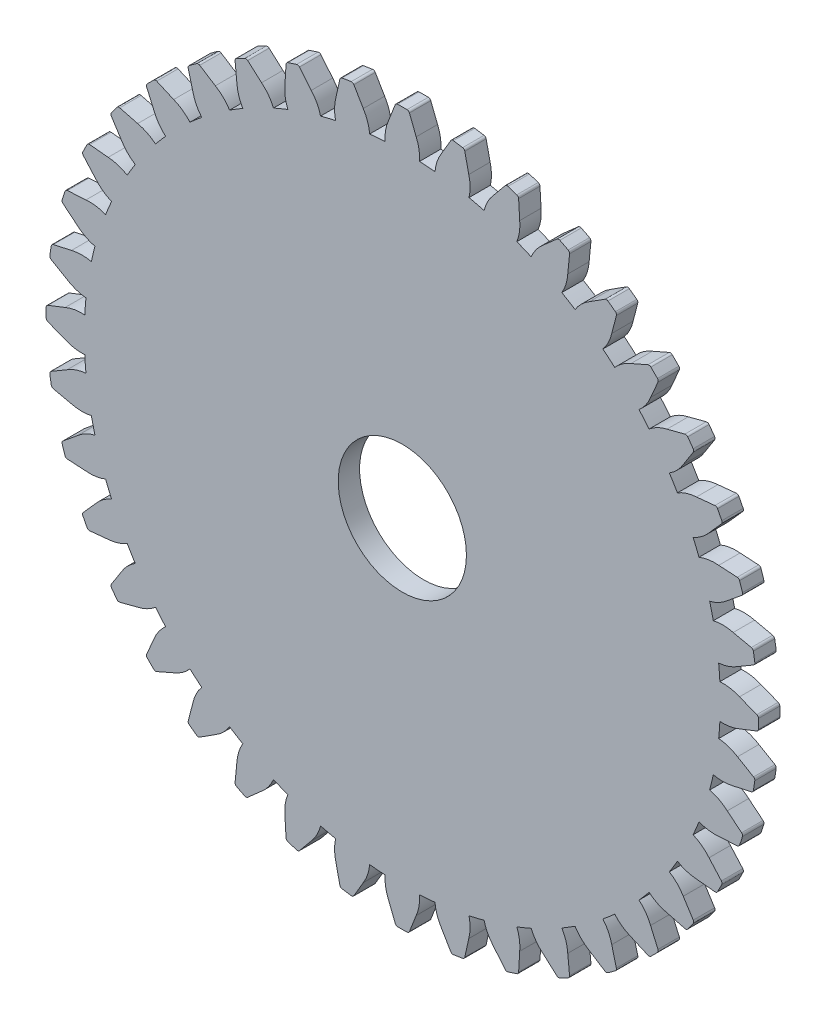
from build123d import *

# Parameters (mm, degrees)
MODEL_R             = 6
BOSS_EXTRUDE1_DEPTH = 2


with BuildPart() as part:
    # Model → Boss-Extrude1 (new body)
    with BuildSketch(Plane.XY):
        with BuildLine():
            ThreePointArc((70.0716993, 43.092854601), (70.049845694, 43.455130485), (70.023576538, 43.817112981))
            ThreePointArc((70.023576538, 43.817112981), (69.992895739, 44.178748273), (69.957807857, 44.539982597))
            ThreePointArc((69.957807857, 44.539982597), (70.876932331, 44.731527399), (71.723910096, 45.136629701))
            ThreePointArc((71.723910096, 45.136629701), (72.472755382, 45.575792344), (73.221545221, 46.015049518))
            ThreePointArc((73.221545221, 46.015049518), (73.320101406, 46.122090017), (73.342139687, 46.265913882))
            ThreePointArc((73.342139687, 46.265913882), (73.310158709, 46.481495249), (73.276769081, 46.696862938))
            ThreePointArc((73.276769081, 46.696862938), (73.241972229, 46.912007745), (73.20576964, 47.126920474))
            ThreePointArc((73.20576964, 47.126920474), (73.14036597, 47.256894894), (73.013556136, 47.328240923))
            ThreePointArc((73.013556136, 47.328240923), (72.165676748, 47.514610535), (71.317773839, 47.700873108))
            ThreePointArc((71.317773839, 47.700873108), (70.387066621, 47.824417769), (69.453736701, 47.722562619))
            ThreePointArc((69.453736701, 47.722562619), (69.375479715, 48.076959629), (69.292907438, 48.430376118))
            ThreePointArc((69.292907438, 48.430376118), (69.206032147, 48.782759545), (69.114866756, 49.134057521))
            ThreePointArc((69.114866756, 49.134057521), (69.992711075, 49.467026835), (70.765889176, 49.999638169))
            ThreePointArc((70.765889176, 49.999638169), (71.436814761, 50.550539202), (72.107670794, 51.10152493))
            ThreePointArc((72.107670794, 51.10152493), (72.188268765, 51.222665166), (72.187536709, 51.368165867))
            ThreePointArc((72.187536709, 51.368165867), (72.122225114, 51.576090143), (72.055555638, 51.78358301))
            ThreePointArc((72.055555638, 51.78358301), (71.98753113, 51.9906356), (71.918154497, 52.197239064))
            ThreePointArc((71.918154497, 52.197239064), (71.833223577, 52.315381896), (71.696814004, 52.366012107))
            ThreePointArc((71.696814004, 52.366012107), (70.830218788, 52.417449642), (69.963617085, 52.468777776))
            ThreePointArc((69.963617085, 52.468777776), (69.025041774, 52.445206711), (68.11913635, 52.198600601))
            ThreePointArc((68.11913635, 52.198600601), (67.986402931, 52.536392305), (67.849560736, 52.872540501))
            ThreePointArc((67.849560736, 52.872540501), (67.708630111, 53.206995214), (67.563632007, 53.539706719))
            ThreePointArc((67.563632007, 53.539706719), (68.378580728, 54.005901734), (69.058920956, 54.652907442))
            ThreePointArc((69.058920956, 54.652907442), (69.635406425, 55.301981854), (70.211809949, 55.951129038))
            ThreePointArc((70.211809949, 55.951129038), (70.272465117, 56.083386138), (70.248980749, 56.226980965))
            ThreePointArc((70.248980749, 56.226980965), (70.151946726, 56.422128363), (70.053639027, 56.616637245))
            ThreePointArc((70.053639027, 56.616637245), (69.954061852, 56.810499296), (69.853219458, 57.003706233))
            ThreePointArc((69.853219458, 57.003706233), (69.750852567, 57.107108407), (69.608202113, 57.135776118))
            ThreePointArc((69.608202113, 57.135776118), (68.744229518, 57.051015013), (67.880267631, 56.966144838))
            ThreePointArc((67.880267631, 56.966144838), (66.956935066, 56.796038446), (66.100760537, 56.410753635))
            ThreePointArc((66.100760537, 56.410753635), (65.916819022, 56.723622481), (65.729076419, 57.0342253))
            ThreePointArc((65.729076419, 57.0342253), (65.537560639, 57.342515913), (65.342300156, 57.648448487))
            ThreePointArc((65.342300156, 57.648448487), (66.074286538, 58.236389935), (66.645036657, 58.981858588))
            ThreePointArc((66.645036657, 58.981858588), (67.112887025, 59.713124013), (67.580645072, 60.444448495))
            ThreePointArc((67.580645072, 60.444448495), (67.619863906, 60.584565849), (67.57420549, 60.722719022))
            ThreePointArc((67.57420549, 60.722719022), (67.447838338, 60.900284366), (67.320313076, 61.077019808))
            ThreePointArc((67.320313076, 61.077019808), (67.191635156, 61.252917794), (67.061810075, 61.427970806))
            ThreePointArc((67.061810075, 61.427970806), (66.944527827, 61.514086218), (66.799149018, 61.520085535))
            ThreePointArc((66.799149018, 61.520085535), (65.959072918, 61.301212889), (65.119024456, 61.082234191))
            ThreePointArc((65.119024456, 61.082234191), (64.23367015, 60.769781055), (63.448308373, 60.255304535))
            ThreePointArc((63.448308373, 60.255304535), (63.217688012, 60.535546654), (62.983667846, 60.812956023))
            ThreePointArc((62.983667846, 60.812956023), (62.746282667, 61.087491399), (62.505567765, 61.359111966))
            ThreePointArc((62.505567765, 61.359111966), (63.136567875, 62.054322777), (63.583674122, 62.879898464))
            ThreePointArc((63.583674122, 62.879898464), (63.93136936, 63.67534872), (64.278964176, 64.470842864))
            ThreePointArc((64.278964176, 64.470842864), (64.295780977, 64.615370318), (64.229072775, 64.744680046))
            ThreePointArc((64.229072775, 64.744680046), (64.076484072, 64.900291088), (63.922881344, 65.054901278))
            ThreePointArc((63.922881344, 65.054901278), (63.768271155, 65.208504006), (63.612660112, 65.361092708))
            ThreePointArc((63.612660112, 65.361092708), (63.483350385, 65.427800911), (63.33882293, 65.410984109))
            ThreePointArc((63.33882293, 65.410984109), (62.543328787, 65.063389294), (61.747878531, 64.715694056))
            ThreePointArc((61.747878531, 64.715694056), (60.922302844, 64.268587808), (60.227092033, 63.637587699))
            ThreePointArc((60.227092033, 63.637587699), (59.955471466, 63.8783026), (59.68093609, 64.11568778))
            ThreePointArc((59.68093609, 64.11568778), (59.403526721, 64.349707946), (59.123284602, 64.580328306))
            ThreePointArc((59.123284602, 64.580328306), (59.637761122, 65.365690083), (59.950214258, 66.251044389))
            ThreePointArc((59.950214258, 66.251044389), (60.169192956, 67.091092852), (60.388065602, 67.931168951))
            ThreePointArc((60.388065602, 67.931168951), (60.382066285, 68.07654776), (60.295950873, 68.193830008))
            ThreePointArc((60.295950873, 68.193830008), (60.120897861, 68.323655089), (59.944999875, 68.45233301))
            ThreePointArc((59.944999875, 68.45233301), (59.768264433, 68.579858271), (59.590699088, 68.706225423))
            ThreePointArc((59.590699088, 68.706225423), (59.452545916, 68.751883839), (59.312428562, 68.712665005))
            ThreePointArc((59.312428562, 68.712665005), (58.58110408, 68.244906958), (57.849838655, 67.77705659))
            ThreePointArc((57.849838655, 67.77705659), (57.104370002, 67.206306472), (56.516428554, 66.474320089))
            ThreePointArc((56.516428554, 66.474320089), (56.21049598, 66.669580572), (55.902205367, 66.861096352))
            ThreePointArc((55.902205367, 66.861096352), (55.591602548, 67.048838955), (55.278733702, 67.23278047))
            ThreePointArc((55.278733702, 67.23278047), (55.664018512, 68.088955), (55.834124905, 69.012287565))
            ThreePointArc((55.834124905, 69.012287565), (55.918995079, 69.876249452), (56.003756185, 70.740222046))
            ThreePointArc((56.003756185, 70.740222046), (55.975088474, 70.882872501), (55.8716863, 70.985239391))
            ThreePointArc((55.8716863, 70.985239391), (55.678479363, 71.086081785), (55.484617312, 71.18565896))
            ThreePointArc((55.484617312, 71.18565896), (55.29010843, 71.283966659), (55.094961032, 71.381000682))
            ThreePointArc((55.094961032, 71.381000682), (54.951366205, 71.40448505), (54.819109105, 71.343829882))
            ThreePointArc((54.819109105, 71.343829882), (54.169961921, 70.767426358), (53.520887509, 70.190940889))
            ThreePointArc((53.520887509, 70.190940889), (52.873881801, 69.510600662), (52.407686786, 68.69565194))
            ThreePointArc((52.407686786, 68.69565194), (52.074975281, 68.840650044), (51.740520568, 68.98158067))
            ThreePointArc((51.740520568, 68.98158067), (51.404372372, 69.118422864), (51.066580667, 69.251156283))
            ThreePointArc((51.066580667, 69.251156283), (51.313186778, 70.157061707), (51.336757843, 71.095637018))
            ThreePointArc((51.336757843, 71.095637018), (51.285429709, 71.962238721), (51.233992174, 72.828833937))
            ThreePointArc((51.233992174, 72.828833937), (51.183361962, 72.96524351), (51.065219131, 73.050174431))
            ThreePointArc((51.065219131, 73.050174431), (50.858615666, 73.119551064), (50.651563076, 73.187575572))
            ThreePointArc((50.651563076, 73.187575572), (50.44407021, 73.254245048), (50.236145934, 73.319556642))
            ThreePointArc((50.236145934, 73.319556642), (50.090645233, 73.320288698), (49.969504996, 73.239690727))
            ThreePointArc((49.969504996, 73.239690727), (49.418519269, 72.568834694), (48.867618235, 71.897909109))
            ThreePointArc((48.867618235, 71.897909109), (48.335006901, 71.124731008), (48.002037588, 70.24688669))
            ThreePointArc((48.002037588, 70.24688669), (47.650739612, 70.33805208), (47.298356185, 70.424927372))
            ThreePointArc((47.298356185, 70.424927372), (46.944939695, 70.507499648), (46.590542686, 70.585756634))
            ThreePointArc((46.590542686, 70.585756634), (46.692397836, 71.519086554), (46.568853175, 72.449793773))
            ThreePointArc((46.568853175, 72.449793773), (46.382590602, 73.297696681), (46.196220989, 74.145576069))
            ThreePointArc((46.196220989, 74.145576069), (46.124874961, 74.272385903), (45.994900541, 74.337789573))
            ThreePointArc((45.994900541, 74.337789573), (45.779987811, 74.373992162), (45.564843005, 74.408789014))
            ThreePointArc((45.564843005, 74.408789014), (45.349475316, 74.442178643), (45.133893949, 74.47415962))
            ThreePointArc((45.133893949, 74.47415962), (44.990070084, 74.452121339), (44.883029585, 74.353565154))
            ThreePointArc((44.883029585, 74.353565154), (44.44377241, 73.604775315), (44.004609768, 72.85593003))
            ThreePointArc((44.004609768, 72.85593003), (43.599507466, 72.008952264), (43.407962664, 71.08982779))
            ThreePointArc((43.407962664, 71.08982779), (43.04672834, 71.124915672), (42.685093048, 71.155596472))
            ThreePointArc((42.685093048, 71.155596472), (42.323110552, 71.181865627), (41.960834668, 71.203719233))
            ThreePointArc((41.960834668, 71.203719233), (41.915430845, 72.141491969), (41.647812538, 73.041413994))
            ThreePointArc((41.647812538, 73.041413994), (41.331201929, 73.849739925), (41.014489277, 74.65802588))
            ThreePointArc((41.014489277, 74.65802588), (40.924184208, 74.772113497), (40.7855786, 74.81637946))
            ThreePointArc((40.7855786, 74.81637946), (40.56764847, 74.818516577), (40.349709026, 74.81922896))
            ThreePointArc((40.349709026, 74.81922896), (40.131769583, 74.818516577), (39.913839453, 74.81637946))
            ThreePointArc((39.913839453, 74.81637946), (39.775233845, 74.772113497), (39.684928776, 74.65802588))
            ThreePointArc((39.684928776, 74.65802588), (39.368216124, 73.849739925), (39.051605515, 73.041413994))
            ThreePointArc((39.051605515, 73.041413994), (38.783987208, 72.141491968), (38.738583385, 71.203719233))
            ThreePointArc((38.738583385, 71.203719233), (38.376307501, 71.181865627), (38.014325005, 71.155596472))
            ThreePointArc((38.014325005, 71.155596472), (37.652689713, 71.124915672), (37.291455389, 71.08982779))
            ThreePointArc((37.291455389, 71.08982779), (37.099910587, 72.008952264), (36.694808285, 72.85593003))
            ThreePointArc((36.694808285, 72.85593003), (36.255645643, 73.604775315), (35.816388468, 74.353565154))
            ThreePointArc((35.816388468, 74.353565154), (35.709347969, 74.452121339), (35.565524104, 74.47415962))
            ThreePointArc((35.565524104, 74.47415962), (35.349942737, 74.442178643), (35.134575048, 74.408789014))
            ThreePointArc((35.134575048, 74.408789014), (34.919430242, 74.373992162), (34.704517512, 74.337789573))
            ThreePointArc((34.704517512, 74.337789573), (34.574543092, 74.272385903), (34.503197064, 74.145576069))
            ThreePointArc((34.503197064, 74.145576069), (34.316827451, 73.297696681), (34.130564878, 72.449793773))
            ThreePointArc((34.130564878, 72.449793773), (34.007020217, 71.519086554), (34.108875367, 70.585756634))
            ThreePointArc((34.108875367, 70.585756634), (33.754478358, 70.507499648), (33.401061868, 70.424927372))
            ThreePointArc((33.401061868, 70.424927372), (33.048678441, 70.33805208), (32.697380465, 70.24688669))
            ThreePointArc((32.697380465, 70.24688669), (32.364411152, 71.124731008), (31.831799817, 71.89790911))
            ThreePointArc((31.831799817, 71.89790911), (31.280898784, 72.568834694), (30.729913057, 73.239690727))
            ThreePointArc((30.729913057, 73.239690727), (30.60877282, 73.320288698), (30.463272119, 73.319556642))
            ThreePointArc((30.463272119, 73.319556642), (30.255347843, 73.254245048), (30.047854976, 73.187575572))
            ThreePointArc((30.047854976, 73.187575572), (29.840802386, 73.119551064), (29.634198922, 73.050174431))
            ThreePointArc((29.634198922, 73.050174431), (29.516056091, 72.96524351), (29.465425879, 72.828833937))
            ThreePointArc((29.465425879, 72.828833937), (29.413988344, 71.962238721), (29.36266021, 71.095637018))
            ThreePointArc((29.36266021, 71.095637018), (29.386231275, 70.157061707), (29.632837386, 69.251156283))
            ThreePointArc((29.632837386, 69.251156283), (29.295045681, 69.118422864), (28.958897485, 68.98158067))
            ThreePointArc((28.958897485, 68.98158067), (28.624442772, 68.840650044), (28.291731267, 68.69565194))
            ThreePointArc((28.291731267, 68.69565194), (27.825536252, 69.510600662), (27.178530544, 70.190940889))
            ThreePointArc((27.178530544, 70.190940889), (26.529456132, 70.767426358), (25.880308948, 71.343829882))
            ThreePointArc((25.880308948, 71.343829882), (25.748051848, 71.40448505), (25.604457021, 71.381000682))
            ThreePointArc((25.604457021, 71.381000682), (25.409309623, 71.283966659), (25.214800741, 71.18565896))
            ThreePointArc((25.214800741, 71.18565896), (25.02093869, 71.086081785), (24.827731753, 70.985239391))
            ThreePointArc((24.827731753, 70.985239391), (24.724329579, 70.882872501), (24.695661868, 70.740222046))
            ThreePointArc((24.695661868, 70.740222046), (24.780422974, 69.876249452), (24.865293148, 69.012287565))
            ThreePointArc((24.865293148, 69.012287565), (25.035399541, 68.088955), (25.420684351, 67.23278047))
            ThreePointArc((25.420684351, 67.23278047), (25.107815505, 67.048838955), (24.797212686, 66.861096352))
            ThreePointArc((24.797212686, 66.861096352), (24.488922073, 66.669580572), (24.182989499, 66.474320089))
            ThreePointArc((24.182989499, 66.474320089), (23.595048051, 67.206306472), (22.849579398, 67.77705659))
            ThreePointArc((22.849579398, 67.77705659), (22.118313973, 68.244906958), (21.386989491, 68.712665005))
            ThreePointArc((21.386989491, 68.712665005), (21.246872137, 68.751883839), (21.108718965, 68.706225423))
            ThreePointArc((21.108718965, 68.706225423), (20.93115362, 68.579858271), (20.754418178, 68.45233301))
            ThreePointArc((20.754418178, 68.45233301), (20.578520192, 68.323655089), (20.40346718, 68.193830008))
            ThreePointArc((20.40346718, 68.193830008), (20.317351768, 68.07654776), (20.311352451, 67.931168951))
            ThreePointArc((20.311352451, 67.931168951), (20.530225097, 67.091092852), (20.749203795, 66.251044389))
            ThreePointArc((20.749203795, 66.251044389), (21.061656931, 65.365690083), (21.576133451, 64.580328306))
            ThreePointArc((21.576133451, 64.580328306), (21.295891332, 64.349707946), (21.018481963, 64.11568778))
            ThreePointArc((21.018481963, 64.11568778), (20.743946587, 63.8783026), (20.47232602, 63.637587699))
            ThreePointArc((20.47232602, 63.637587699), (19.777115209, 64.268587808), (18.951539522, 64.715694056))
            ThreePointArc((18.951539522, 64.715694056), (18.156089266, 65.063389294), (17.360595123, 65.410984109))
            ThreePointArc((17.360595123, 65.410984109), (17.216067668, 65.427800911), (17.086757941, 65.361092708))
            ThreePointArc((17.086757941, 65.361092708), (16.931146898, 65.208504006), (16.776536709, 65.054901278))
            ThreePointArc((16.776536709, 65.054901278), (16.622933981, 64.900291088), (16.470345278, 64.744680046))
            ThreePointArc((16.470345278, 64.744680046), (16.403637076, 64.615370318), (16.420453877, 64.470842864))
            ThreePointArc((16.420453877, 64.470842864), (16.768048693, 63.67534872), (17.115743931, 62.879898464))
            ThreePointArc((17.115743931, 62.879898464), (17.562850178, 62.054322777), (18.193850288, 61.359111966))
            ThreePointArc((18.193850288, 61.359111966), (17.953135386, 61.087491399), (17.715750207, 60.812956023))
            ThreePointArc((17.715750207, 60.812956023), (17.481730041, 60.535546654), (17.25110968, 60.255304535))
            ThreePointArc((17.25110968, 60.255304535), (16.465747903, 60.769781055), (15.580393597, 61.082234191))
            ThreePointArc((15.580393597, 61.082234191), (14.740345135, 61.301212889), (13.900269035, 61.520085535))
            ThreePointArc((13.900269035, 61.520085535), (13.754890226, 61.514086218), (13.637607978, 61.427970806))
            ThreePointArc((13.637607978, 61.427970806), (13.507782897, 61.252917794), (13.379104976, 61.077019808))
            ThreePointArc((13.379104976, 61.077019808), (13.251579715, 60.900284366), (13.125212563, 60.722719022))
            ThreePointArc((13.125212563, 60.722719022), (13.079554147, 60.584565849), (13.118772981, 60.444448495))
            ThreePointArc((13.118772981, 60.444448495), (13.586531028, 59.713124013), (14.054381396, 58.981858588))
            ThreePointArc((14.054381396, 58.981858588), (14.625131515, 58.236389935), (15.357117897, 57.648448487))
            ThreePointArc((15.357117897, 57.648448487), (15.161857414, 57.342515913), (14.970341634, 57.0342253))
            ThreePointArc((14.970341634, 57.0342253), (14.782599031, 56.723622481), (14.598657516, 56.410753635))
            ThreePointArc((14.598657516, 56.410753635), (13.742482987, 56.796038446), (12.819150421, 56.966144838))
            ThreePointArc((12.819150421, 56.966144838), (11.955188535, 57.051015013), (11.09121594, 57.135776118))
            ThreePointArc((11.09121594, 57.135776118), (10.948565486, 57.107108407), (10.846198595, 57.003706233))
            ThreePointArc((10.846198595, 57.003706233), (10.745356201, 56.810499296), (10.645779026, 56.616637245))
            ThreePointArc((10.645779026, 56.616637245), (10.547471327, 56.422128363), (10.450437304, 56.226980965))
            ThreePointArc((10.450437304, 56.226980965), (10.426952936, 56.083386138), (10.487608104, 55.951129038))
            ThreePointArc((10.487608104, 55.951129038), (11.064011628, 55.301981854), (11.640497097, 54.652907442))
            ThreePointArc((11.640497097, 54.652907442), (12.320837325, 54.005901734), (13.135786046, 53.539706719))
            ThreePointArc((13.135786046, 53.539706719), (12.990787942, 53.206995214), (12.849857317, 52.872540501))
            ThreePointArc((12.849857317, 52.872540501), (12.713015122, 52.536392305), (12.580281703, 52.198600601))
            ThreePointArc((12.580281703, 52.198600601), (11.674376279, 52.445206711), (10.735800968, 52.468777776))
            ThreePointArc((10.735800968, 52.468777776), (9.869199265, 52.417449642), (9.002604049, 52.366012107))
            ThreePointArc((9.002604049, 52.366012107), (8.866194476, 52.315381896), (8.781263556, 52.197239064))
            ThreePointArc((8.781263556, 52.197239064), (8.711886923, 51.9906356), (8.643862414, 51.78358301))
            ThreePointArc((8.643862414, 51.78358301), (8.577192939, 51.576090143), (8.511881344, 51.368165867))
            ThreePointArc((8.511881344, 51.368165867), (8.511149288, 51.222665166), (8.591747259, 51.10152493))
            ThreePointArc((8.591747259, 51.10152493), (9.262603292, 50.550539202), (9.933528877, 49.999638169))
            ThreePointArc((9.933528877, 49.999638169), (10.706706978, 49.467026834), (11.584551297, 49.134057521))
            ThreePointArc((11.584551297, 49.134057521), (11.493385906, 48.782759545), (11.406510615, 48.430376118))
            ThreePointArc((11.406510615, 48.430376118), (11.323938338, 48.076959629), (11.245681352, 47.722562619))
            ThreePointArc((11.245681352, 47.722562619), (10.312351432, 47.824417769), (9.381644214, 47.700873108))
            ThreePointArc((9.381644214, 47.700873108), (8.533741305, 47.514610535), (7.685861917, 47.328240923))
            ThreePointArc((7.685861917, 47.328240923), (7.559052083, 47.256894894), (7.493648413, 47.126920474))
            ThreePointArc((7.493648413, 47.126920474), (7.457445824, 46.912007745), (7.422648972, 46.696862938))
            ThreePointArc((7.422648972, 46.696862938), (7.389259344, 46.481495249), (7.357278366, 46.265913882))
            ThreePointArc((7.357278366, 46.265913882), (7.379316647, 46.122090017), (7.477872832, 46.015049518))
            ThreePointArc((7.477872832, 46.015049518), (8.226662671, 45.575792344), (8.975507957, 45.136629701))
            ThreePointArc((8.975507957, 45.136629701), (9.822485722, 44.731527399), (10.741610196, 44.539982597))
            ThreePointArc((10.741610196, 44.539982597), (10.706522314, 44.178748273), (10.675841515, 43.817112981))
            ThreePointArc((10.675841515, 43.817112981), (10.649572359, 43.455130485), (10.627718753, 43.092854601))
            ThreePointArc((10.627718753, 43.092854601), (9.689946018, 43.047450778), (8.790023992, 42.779832472))
            ThreePointArc((8.790023992, 42.779832472), (7.981698061, 42.463221862), (7.173412107, 42.14650921))
            ThreePointArc((7.173412107, 42.14650921), (7.059324489, 42.056204141), (7.015058526, 41.917598533))
            ThreePointArc((7.015058526, 41.917598533), (7.012921409, 41.699668404), (7.012209026, 41.48172896))
            ThreePointArc((7.012209026, 41.48172896), (7.012921409, 41.263789516), (7.015058526, 41.045859386))
            ThreePointArc((7.015058526, 41.045859386), (7.059324489, 40.907253778), (7.173412107, 40.81694871))
            ThreePointArc((7.173412107, 40.81694871), (7.981698061, 40.500236058), (8.790023992, 40.183625448))
            ThreePointArc((8.790023992, 40.183625448), (9.689946018, 39.916007141), (10.627718753, 39.870603318))
            ThreePointArc((10.627718753, 39.870603318), (10.649572359, 39.508327435), (10.675841515, 39.146344938))
            ThreePointArc((10.675841515, 39.146344938), (10.706522314, 38.784709646), (10.741610196, 38.423475323))
            ThreePointArc((10.741610196, 38.423475323), (9.822485722, 38.23193052), (8.975507957, 37.826828218))
            ThreePointArc((8.975507957, 37.826828218), (8.226662671, 37.387665576), (7.477872832, 36.948408401))
            ThreePointArc((7.477872832, 36.948408401), (7.379316647, 36.841367902), (7.357278366, 36.697544037))
            ThreePointArc((7.357278366, 36.697544037), (7.389259344, 36.48196267), (7.422648972, 36.266594981))
            ThreePointArc((7.422648972, 36.266594981), (7.457445824, 36.051450175), (7.493648413, 35.836537445))
            ThreePointArc((7.493648413, 35.836537445), (7.559052083, 35.706563025), (7.685861917, 35.635216997))
            ThreePointArc((7.685861917, 35.635216997), (8.533741305, 35.448847384), (9.381644213, 35.262584811))
            ThreePointArc((9.381644213, 35.262584811), (10.312351432, 35.13904015), (11.245681352, 35.2408953))
            ThreePointArc((11.245681352, 35.2408953), (11.323938338, 34.886498291), (11.406510615, 34.533081801))
            ThreePointArc((11.406510615, 34.533081801), (11.493385906, 34.180698374), (11.584551297, 33.829400398))
            ThreePointArc((11.584551297, 33.829400398), (10.706706978, 33.496431085), (9.933528877, 32.963819751))
            ThreePointArc((9.933528877, 32.963819751), (9.262603292, 32.412918718), (8.591747259, 31.86193299))
            ThreePointArc((8.591747259, 31.86193299), (8.511149288, 31.740792753), (8.511881344, 31.595292052))
            ThreePointArc((8.511881344, 31.595292052), (8.577192939, 31.387367776), (8.643862414, 31.17987491))
            ThreePointArc((8.643862414, 31.17987491), (8.711886923, 30.97282232), (8.781263556, 30.766218855))
            ThreePointArc((8.781263556, 30.766218855), (8.866194476, 30.648076024), (9.002604049, 30.597445812))
            ThreePointArc((9.002604049, 30.597445812), (9.869199265, 30.546008277), (10.735800968, 30.494680143))
            ThreePointArc((10.735800968, 30.494680143), (11.674376279, 30.518251208), (12.580281703, 30.764857319))
            ThreePointArc((12.580281703, 30.764857319), (12.713015122, 30.427065615), (12.849857317, 30.090917418))
            ThreePointArc((12.849857317, 30.090917418), (12.990787942, 29.756462705), (13.135786046, 29.4237512))
            ThreePointArc((13.135786046, 29.4237512), (12.320837325, 28.957556185), (11.640497097, 28.310550477))
            ThreePointArc((11.640497097, 28.310550477), (11.064011628, 27.661476065), (10.487608104, 27.012328882))
            ThreePointArc((10.487608104, 27.012328882), (10.426952936, 26.880071782), (10.450437304, 26.736476954))
            ThreePointArc((10.450437304, 26.736476954), (10.547471327, 26.541329556), (10.645779026, 26.346820675))
            ThreePointArc((10.645779026, 26.346820675), (10.745356201, 26.152958623), (10.846198595, 25.959751687))
            ThreePointArc((10.846198595, 25.959751687), (10.948565486, 25.856349513), (11.09121594, 25.827681801))
            ThreePointArc((11.09121594, 25.827681801), (11.955188535, 25.912442907), (12.819150421, 25.997313081))
            ThreePointArc((12.819150421, 25.997313081), (13.742482986, 26.167419474), (14.598657516, 26.552704285))
            ThreePointArc((14.598657516, 26.552704285), (14.782599031, 26.239835438), (14.970341634, 25.929232619))
            ThreePointArc((14.970341634, 25.929232619), (15.161857414, 25.620942006), (15.357117897, 25.315009432))
            ThreePointArc((15.357117897, 25.315009432), (14.625131515, 24.727067984), (14.054381396, 23.981599331))
            ThreePointArc((14.054381396, 23.981599331), (13.586531028, 23.250333906), (13.118772981, 22.519009424))
            ThreePointArc((13.118772981, 22.519009424), (13.079554147, 22.37889207), (13.125212563, 22.240738898))
            ThreePointArc((13.125212563, 22.240738898), (13.251579715, 22.063173553), (13.379104976, 21.886438111))
            ThreePointArc((13.379104976, 21.886438111), (13.507782897, 21.710540125), (13.637607978, 21.535487113))
            ThreePointArc((13.637607978, 21.535487113), (13.754890226, 21.449371701), (13.900269035, 21.443372385))
            ThreePointArc((13.900269035, 21.443372385), (14.740345135, 21.662245031), (15.580393597, 21.881223728))
            ThreePointArc((15.580393597, 21.881223728), (16.465747903, 22.193676865), (17.25110968, 22.708153384))
            ThreePointArc((17.25110968, 22.708153384), (17.481730041, 22.427911265), (17.715750207, 22.150501896))
            ThreePointArc((17.715750207, 22.150501896), (17.953135386, 21.87596652), (18.193850288, 21.604345953))
            ThreePointArc((18.193850288, 21.604345953), (17.562850178, 20.909135142), (17.115743931, 20.083559456))
            ThreePointArc((17.115743931, 20.083559456), (16.768048693, 19.2881092), (16.420453877, 18.492615056))
            ThreePointArc((16.420453877, 18.492615056), (16.403637076, 18.348087601), (16.470345278, 18.218777874))
            ThreePointArc((16.470345278, 18.218777874), (16.622933981, 18.063166831), (16.776536709, 17.908556642))
            ThreePointArc((16.776536709, 17.908556642), (16.931146898, 17.754953914), (17.086757941, 17.602365211))
            ThreePointArc((17.086757941, 17.602365211), (17.216067668, 17.535657009), (17.360595123, 17.55247381))
            ThreePointArc((17.360595123, 17.55247381), (18.156089266, 17.900068626), (18.951539522, 18.247763864))
            ThreePointArc((18.951539522, 18.247763864), (19.777115209, 18.694870111), (20.47232602, 19.325870221))
            ThreePointArc((20.47232602, 19.325870221), (20.743946587, 19.08515532), (21.018481963, 18.84777014))
            ThreePointArc((21.018481963, 18.84777014), (21.295891332, 18.613749974), (21.576133451, 18.383129613))
            ThreePointArc((21.576133451, 18.383129613), (21.061656931, 17.597767836), (20.749203795, 16.71241353))
            ThreePointArc((20.749203795, 16.71241353), (20.530225097, 15.872365068), (20.311352451, 15.032288968))
            ThreePointArc((20.311352451, 15.032288968), (20.317351768, 14.886910159), (20.40346718, 14.769627911))
            ThreePointArc((20.40346718, 14.769627911), (20.578520192, 14.63980283), (20.754418178, 14.51112491))
            ThreePointArc((20.754418178, 14.51112491), (20.93115362, 14.383599648), (21.108718965, 14.257232496))
            ThreePointArc((21.108718965, 14.257232496), (21.246872137, 14.21157408), (21.386989491, 14.250792914))
            ThreePointArc((21.386989491, 14.250792914), (22.118313973, 14.718550962), (22.849579398, 15.18640133))
            ThreePointArc((22.849579398, 15.18640133), (23.595048051, 15.757151448), (24.182989499, 16.48913783))
            ThreePointArc((24.182989499, 16.48913783), (24.488922073, 16.293877347), (24.797212686, 16.102361568))
            ThreePointArc((24.797212686, 16.102361568), (25.107815505, 15.914618964), (25.420684351, 15.730677449))
            ThreePointArc((25.420684351, 15.730677449), (25.035399541, 14.87450292), (24.865293148, 13.951170355))
            ThreePointArc((24.865293148, 13.951170355), (24.780422974, 13.087208468), (24.695661868, 12.223235874))
            ThreePointArc((24.695661868, 12.223235874), (24.724329579, 12.080585419), (24.827731753, 11.978218528))
            ThreePointArc((24.827731753, 11.978218528), (25.02093869, 11.877376134), (25.214800741, 11.77779896))
            ThreePointArc((25.214800741, 11.77779896), (25.409309623, 11.67949126), (25.604457021, 11.582457237))
            ThreePointArc((25.604457021, 11.582457237), (25.748051848, 11.55897287), (25.880308948, 11.619628038))
            ThreePointArc((25.880308948, 11.619628038), (26.529456132, 12.196031562), (27.178530544, 12.772517031))
            ThreePointArc((27.178530544, 12.772517031), (27.825536252, 13.452857258), (28.291731267, 14.267805979))
            ThreePointArc((28.291731267, 14.267805979), (28.624442772, 14.122807875), (28.958897485, 13.98187725))
            ThreePointArc((28.958897485, 13.98187725), (29.295045681, 13.845035055), (29.632837386, 13.712301636))
            ThreePointArc((29.632837386, 13.712301636), (29.386231275, 12.806396213), (29.36266021, 11.867820901))
            ThreePointArc((29.36266021, 11.867820901), (29.413988344, 11.001219198), (29.465425879, 10.134623982))
            ThreePointArc((29.465425879, 10.134623982), (29.516056091, 9.998214409), (29.634198922, 9.913283489))
            ThreePointArc((29.634198922, 9.913283489), (29.840802386, 9.843906856), (30.047854976, 9.775882348))
            ThreePointArc((30.047854976, 9.775882348), (30.255347843, 9.709212872), (30.463272119, 9.643901278))
            ThreePointArc((30.463272119, 9.643901278), (30.60877282, 9.643169222), (30.729913057, 9.723767193))
            ThreePointArc((30.729913057, 9.723767193), (31.280898784, 10.394623225), (31.831799817, 11.06554881))
            ThreePointArc((31.831799817, 11.06554881), (32.364411152, 11.838726912), (32.697380465, 12.71657123))
            ThreePointArc((32.697380465, 12.71657123), (33.048678441, 12.625405839), (33.401061868, 12.538530548))
            ThreePointArc((33.401061868, 12.538530548), (33.754478358, 12.455958271), (34.108875367, 12.377701285))
            ThreePointArc((34.108875367, 12.377701285), (34.007020217, 11.444371366), (34.130564878, 10.513664147))
            ThreePointArc((34.130564878, 10.513664147), (34.316827451, 9.665761238), (34.503197064, 8.817881851))
            ThreePointArc((34.503197064, 8.817881851), (34.574543092, 8.691072016), (34.704517512, 8.625668347))
            ThreePointArc((34.704517512, 8.625668347), (34.919430242, 8.589465757), (35.134575048, 8.554668905))
            ThreePointArc((35.134575048, 8.554668905), (35.349942737, 8.521279277), (35.565524104, 8.489298299))
            ThreePointArc((35.565524104, 8.489298299), (35.709347969, 8.511336581), (35.816388468, 8.609892765))
            ThreePointArc((35.816388468, 8.609892765), (36.255645643, 9.358682604), (36.694808285, 10.10752789))
            ThreePointArc((36.694808285, 10.10752789), (37.099910587, 10.954505655), (37.291455389, 11.87363013))
            ThreePointArc((37.291455389, 11.87363013), (37.652689713, 11.838542247), (38.014325005, 11.807861448))
            ThreePointArc((38.014325005, 11.807861448), (38.376307501, 11.781592292), (38.738583385, 11.759738686))
            ThreePointArc((38.738583385, 11.759738686), (38.783987208, 10.821965951), (39.051605515, 9.922043925))
            ThreePointArc((39.051605515, 9.922043925), (39.368216124, 9.113717995), (39.684928776, 8.30543204))
            ThreePointArc((39.684928776, 8.30543204), (39.775233845, 8.191344422), (39.913839453, 8.14707846))
            ThreePointArc((39.913839453, 8.14707846), (40.131769583, 8.144941342), (40.349709026, 8.14422896))
            ThreePointArc((40.349709026, 8.14422896), (40.56764847, 8.144941342), (40.7855786, 8.14707846))
            ThreePointArc((40.7855786, 8.14707846), (40.924184208, 8.191344422), (41.014489277, 8.30543204))
            ThreePointArc((41.014489277, 8.30543204), (41.331201929, 9.113717994), (41.647812538, 9.922043925))
            ThreePointArc((41.647812538, 9.922043925), (41.915430845, 10.821965951), (41.960834668, 11.759738686))
            ThreePointArc((41.960834668, 11.759738686), (42.323110552, 11.781592292), (42.685093048, 11.807861448))
            ThreePointArc((42.685093048, 11.807861448), (43.04672834, 11.838542247), (43.407962664, 11.87363013))
            ThreePointArc((43.407962664, 11.87363013), (43.599507466, 10.954505655), (44.004609768, 10.10752789))
            ThreePointArc((44.004609768, 10.10752789), (44.44377241, 9.358682604), (44.883029585, 8.609892765))
            ThreePointArc((44.883029585, 8.609892765), (44.990070084, 8.511336581), (45.133893949, 8.489298299))
            ThreePointArc((45.133893949, 8.489298299), (45.349475316, 8.521279277), (45.564843005, 8.554668905))
            ThreePointArc((45.564843005, 8.554668905), (45.779987811, 8.589465757), (45.994900541, 8.625668347))
            ThreePointArc((45.994900541, 8.625668347), (46.124874961, 8.691072016), (46.196220989, 8.817881851))
            ThreePointArc((46.196220989, 8.817881851), (46.382590602, 9.665761238), (46.568853175, 10.513664147))
            ThreePointArc((46.568853175, 10.513664147), (46.692397836, 11.444371366), (46.590542686, 12.377701285))
            ThreePointArc((46.590542686, 12.377701285), (46.944939695, 12.455958271), (47.298356185, 12.538530548))
            ThreePointArc((47.298356185, 12.538530548), (47.650739612, 12.625405839), (48.002037588, 12.71657123))
            ThreePointArc((48.002037588, 12.71657123), (48.335006901, 11.838726912), (48.867618236, 11.06554881))
            ThreePointArc((48.867618236, 11.06554881), (49.418519269, 10.394623225), (49.969504996, 9.723767193))
            ThreePointArc((49.969504996, 9.723767193), (50.090645233, 9.643169222), (50.236145934, 9.643901278))
            ThreePointArc((50.236145934, 9.643901278), (50.44407021, 9.709212872), (50.651563076, 9.775882348))
            ThreePointArc((50.651563076, 9.775882348), (50.858615666, 9.843906856), (51.065219131, 9.913283489))
            ThreePointArc((51.065219131, 9.913283489), (51.183361962, 9.998214409), (51.233992174, 10.134623982))
            ThreePointArc((51.233992174, 10.134623982), (51.285429709, 11.001219198), (51.336757843, 11.867820901))
            ThreePointArc((51.336757843, 11.867820901), (51.313186778, 12.806396213), (51.066580667, 13.712301636))
            ThreePointArc((51.066580667, 13.712301636), (51.404372372, 13.845035055), (51.740520568, 13.98187725))
            ThreePointArc((51.740520568, 13.98187725), (52.074975281, 14.122807875), (52.407686786, 14.267805979))
            ThreePointArc((52.407686786, 14.267805979), (52.873881801, 13.452857258), (53.520887509, 12.772517031))
            ThreePointArc((53.520887509, 12.772517031), (54.169961921, 12.196031562), (54.819109105, 11.619628038))
            ThreePointArc((54.819109105, 11.619628038), (54.951366205, 11.55897287), (55.094961032, 11.582457237))
            ThreePointArc((55.094961032, 11.582457237), (55.29010843, 11.67949126), (55.484617312, 11.77779896))
            ThreePointArc((55.484617312, 11.77779896), (55.678479363, 11.877376134), (55.8716863, 11.978218528))
            ThreePointArc((55.8716863, 11.978218528), (55.975088474, 12.080585419), (56.003756185, 12.223235874))
            ThreePointArc((56.003756185, 12.223235874), (55.918995079, 13.087208468), (55.834124905, 13.951170355))
            ThreePointArc((55.834124905, 13.951170355), (55.664018512, 14.87450292), (55.278733702, 15.730677449))
            ThreePointArc((55.278733702, 15.730677449), (55.591602548, 15.914618964), (55.902205367, 16.102361568))
            ThreePointArc((55.902205367, 16.102361568), (56.21049598, 16.293877347), (56.516428554, 16.48913783))
            ThreePointArc((56.516428554, 16.48913783), (57.104370002, 15.757151448), (57.849838655, 15.186401329))
            ThreePointArc((57.849838655, 15.186401329), (58.58110408, 14.718550962), (59.312428562, 14.250792914))
            ThreePointArc((59.312428562, 14.250792914), (59.452545916, 14.21157408), (59.590699088, 14.257232496))
            ThreePointArc((59.590699088, 14.257232496), (59.768264433, 14.383599648), (59.944999875, 14.51112491))
            ThreePointArc((59.944999875, 14.51112491), (60.120897861, 14.63980283), (60.295950873, 14.769627911))
            ThreePointArc((60.295950873, 14.769627911), (60.382066285, 14.886910159), (60.388065602, 15.032288968))
            ThreePointArc((60.388065602, 15.032288968), (60.169192956, 15.872365068), (59.950214258, 16.71241353))
            ThreePointArc((59.950214258, 16.71241353), (59.637761122, 17.597767836), (59.123284602, 18.383129613))
            ThreePointArc((59.123284602, 18.383129613), (59.403526721, 18.613749974), (59.68093609, 18.84777014))
            ThreePointArc((59.68093609, 18.84777014), (59.955471466, 19.08515532), (60.227092033, 19.325870221))
            ThreePointArc((60.227092033, 19.325870221), (60.922302844, 18.694870111), (61.747878531, 18.247763864))
            ThreePointArc((61.747878531, 18.247763864), (62.543328787, 17.900068626), (63.33882293, 17.55247381))
            ThreePointArc((63.33882293, 17.55247381), (63.483350385, 17.535657009), (63.612660112, 17.602365211))
            ThreePointArc((63.612660112, 17.602365211), (63.768271155, 17.754953914), (63.922881344, 17.908556642))
            ThreePointArc((63.922881344, 17.908556642), (64.076484072, 18.063166831), (64.229072775, 18.218777874))
            ThreePointArc((64.229072775, 18.218777874), (64.295780977, 18.348087601), (64.278964176, 18.492615056))
            ThreePointArc((64.278964176, 18.492615056), (63.93136936, 19.2881092), (63.583674122, 20.083559456))
            ThreePointArc((63.583674122, 20.083559456), (63.136567875, 20.909135142), (62.505567765, 21.604345953))
            ThreePointArc((62.505567765, 21.604345953), (62.746282667, 21.87596652), (62.983667846, 22.150501896))
            ThreePointArc((62.983667846, 22.150501896), (63.217688012, 22.427911265), (63.448308373, 22.708153384))
            ThreePointArc((63.448308373, 22.708153384), (64.23367015, 22.193676865), (65.119024456, 21.881223728))
            ThreePointArc((65.119024456, 21.881223728), (65.959072918, 21.662245031), (66.799149018, 21.443372385))
            ThreePointArc((66.799149018, 21.443372385), (66.944527827, 21.449371701), (67.061810075, 21.535487113))
            ThreePointArc((67.061810075, 21.535487113), (67.191635156, 21.710540125), (67.320313076, 21.886438111))
            ThreePointArc((67.320313076, 21.886438111), (67.447838338, 22.063173553), (67.57420549, 22.240738898))
            ThreePointArc((67.57420549, 22.240738898), (67.619863906, 22.37889207), (67.580645072, 22.519009424))
            ThreePointArc((67.580645072, 22.519009424), (67.112887025, 23.250333906), (66.645036657, 23.981599331))
            ThreePointArc((66.645036657, 23.981599331), (66.074286538, 24.727067984), (65.342300156, 25.315009432))
            ThreePointArc((65.342300156, 25.315009432), (65.537560639, 25.620942006), (65.729076419, 25.929232619))
            ThreePointArc((65.729076419, 25.929232619), (65.916819022, 26.239835438), (66.100760537, 26.552704285))
            ThreePointArc((66.100760537, 26.552704285), (66.956935066, 26.167419474), (67.880267632, 25.997313081))
            ThreePointArc((67.880267632, 25.997313081), (68.744229518, 25.912442907), (69.608202113, 25.827681801))
            ThreePointArc((69.608202113, 25.827681801), (69.750852567, 25.856349513), (69.853219458, 25.959751687))
            ThreePointArc((69.853219458, 25.959751687), (69.954061852, 26.152958623), (70.053639027, 26.346820675))
            ThreePointArc((70.053639027, 26.346820675), (70.151946726, 26.541329556), (70.248980749, 26.736476954))
            ThreePointArc((70.248980749, 26.736476954), (70.272465117, 26.880071782), (70.211809949, 27.012328882))
            ThreePointArc((70.211809949, 27.012328882), (69.635406425, 27.661476065), (69.058920956, 28.310550477))
            ThreePointArc((69.058920956, 28.310550477), (68.378580728, 28.957556185), (67.563632007, 29.4237512))
            ThreePointArc((67.563632007, 29.4237512), (67.708630111, 29.756462705), (67.849560736, 30.090917418))
            ThreePointArc((67.849560736, 30.090917418), (67.986402931, 30.427065615), (68.11913635, 30.764857319))
            ThreePointArc((68.11913635, 30.764857319), (69.025041774, 30.518251208), (69.963617085, 30.494680143))
            ThreePointArc((69.963617085, 30.494680143), (70.830218788, 30.546008277), (71.696814004, 30.597445812))
            ThreePointArc((71.696814004, 30.597445812), (71.833223577, 30.648076024), (71.918154497, 30.766218855))
            ThreePointArc((71.918154497, 30.766218855), (71.98753113, 30.97282232), (72.055555638, 31.17987491))
            ThreePointArc((72.055555638, 31.17987491), (72.122225114, 31.387367776), (72.187536709, 31.595292052))
            ThreePointArc((72.187536709, 31.595292052), (72.188268765, 31.740792753), (72.107670794, 31.86193299))
            ThreePointArc((72.107670794, 31.86193299), (71.436814761, 32.412918718), (70.765889176, 32.963819751))
            ThreePointArc((70.765889176, 32.963819751), (69.992711074, 33.496431085), (69.114866756, 33.829400398))
            ThreePointArc((69.114866756, 33.829400398), (69.206032147, 34.180698374), (69.292907438, 34.533081801))
            ThreePointArc((69.292907438, 34.533081801), (69.375479715, 34.886498291), (69.453736701, 35.2408953))
            ThreePointArc((69.453736701, 35.2408953), (70.387066621, 35.13904015), (71.317773839, 35.262584811))
            ThreePointArc((71.317773839, 35.262584811), (72.165676748, 35.448847384), (73.013556136, 35.635216997))
            ThreePointArc((73.013556136, 35.635216997), (73.14036597, 35.706563025), (73.20576964, 35.836537445))
            ThreePointArc((73.20576964, 35.836537445), (73.241972229, 36.051450175), (73.276769081, 36.266594981))
            ThreePointArc((73.276769081, 36.266594981), (73.310158709, 36.48196267), (73.342139687, 36.697544037))
            ThreePointArc((73.342139687, 36.697544037), (73.320101406, 36.841367902), (73.221545221, 36.948408401))
            ThreePointArc((73.221545221, 36.948408401), (72.472755382, 37.387665576), (71.723910096, 37.826828218))
            ThreePointArc((71.723910096, 37.826828218), (70.876932331, 38.23193052), (69.957807857, 38.423475323))
            ThreePointArc((69.957807857, 38.423475323), (69.992895739, 38.784709646), (70.023576538, 39.146344938))
            ThreePointArc((70.023576538, 39.146344938), (70.049845694, 39.508327435), (70.0716993, 39.870603318))
            ThreePointArc((70.0716993, 39.870603318), (71.009472035, 39.916007141), (71.909394061, 40.183625448))
            ThreePointArc((71.909394061, 40.183625448), (72.717719992, 40.500236058), (73.526005946, 40.81694871))
            ThreePointArc((73.526005946, 40.81694871), (73.640093564, 40.907253778), (73.684359527, 41.045859386))
            ThreePointArc((73.684359527, 41.045859386), (73.686496644, 41.263789516), (73.687209026, 41.48172896))
            ThreePointArc((73.687209026, 41.48172896), (73.686496644, 41.699668404), (73.684359527, 41.917598533))
            ThreePointArc((73.684359527, 41.917598533), (73.640093564, 42.056204141), (73.526005946, 42.14650921))
            ThreePointArc((73.526005946, 42.14650921), (72.717719992, 42.463221862), (71.909394061, 42.779832472))
            ThreePointArc((71.909394061, 42.779832472), (71.009472035, 43.047450778), (70.0716993, 43.092854601))
        make_face()
        with Locations((40.349709026, 41.48172896)):
            Circle(MODEL_R, mode=Mode.SUBTRACT)
    extrude(amount=BOSS_EXTRUDE1_DEPTH)


solid = part.part
